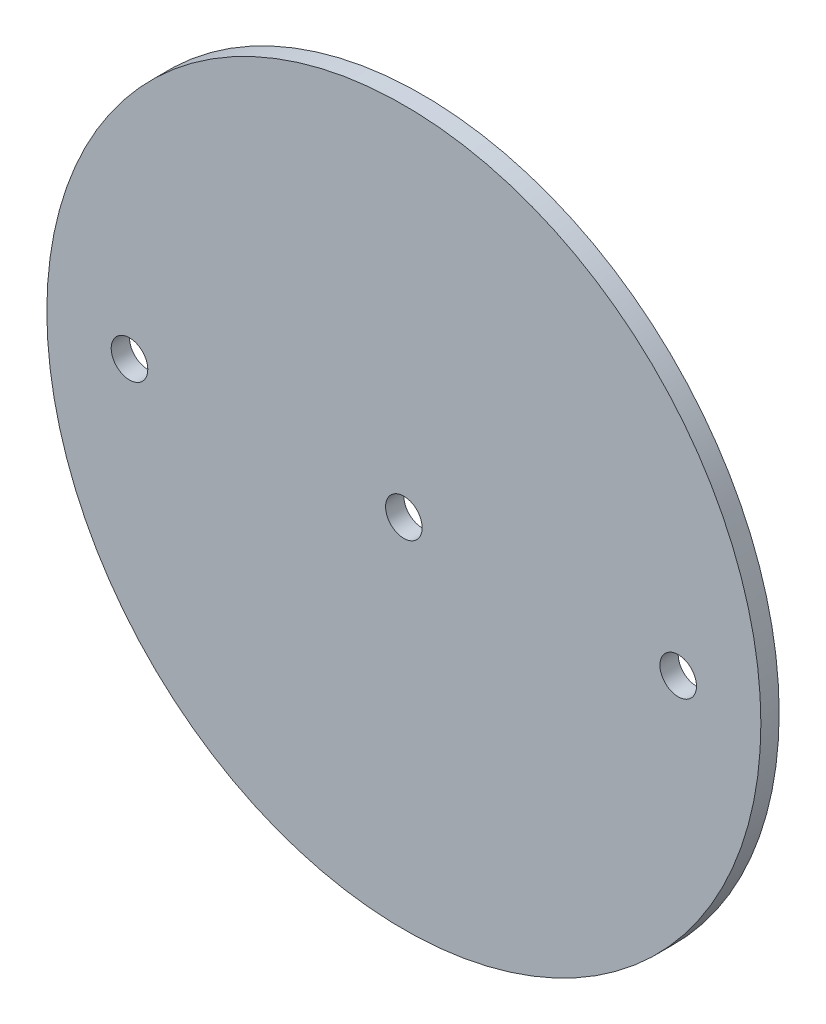
from build123d import *

# Parameters (mm, degrees)
SKETCH1_R                   = 61.976
BOSS_EXTRUDE1_DEPTH         = 1.5875
F_1_4_0_25_DIAMETER_HOLE1_D = 6.35


with BuildPart() as part:
    # Sketch1 → Boss-Extrude1 (new body, symmetric)
    with BuildSketch(Plane.XY):
        Circle(SKETCH1_R)
    extrude(amount=BOSS_EXTRUDE1_DEPTH, both=True)

    # 1/4 (0.25) Diameter Hole1 (through all)
    with Locations(Plane.XY.offset(1.5875)):
        with Locations((-47.625, 0), (0, 0), (47.625, 0)):
            Hole(F_1_4_0_25_DIAMETER_HOLE1_D / 2)


solid = part.part
